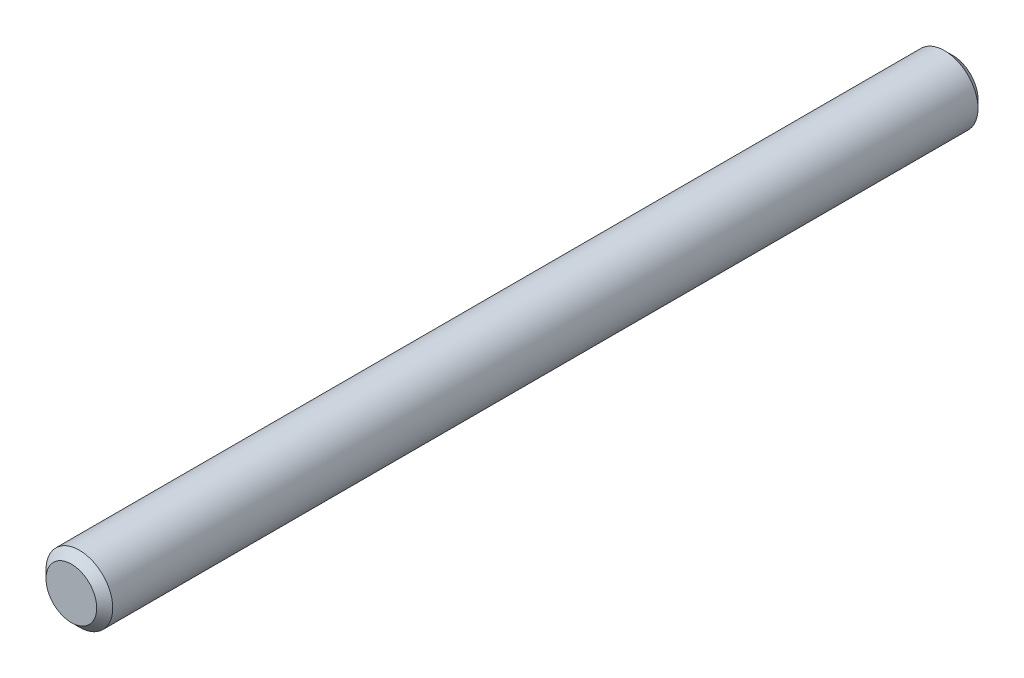
from build123d import *

# Parameters (mm, degrees)
SKETCH1_R           = 12.5
BOSS_EXTRUDE1_DEPTH = 165
CHAMFER1_SIZE       = 3


with BuildPart() as part:
    # Sketch1 → Boss-Extrude1 (new body, symmetric)
    with BuildSketch(Plane.XY):
        Circle(SKETCH1_R)
    extrude(amount=BOSS_EXTRUDE1_DEPTH, both=True)

    # Chamfer1
    chamfer1_edges = [part.edges().sort_by_distance(p)[0] for p in [
        (-12.5, 0, -165),
        (-12.5, 0, 165),
    ]]
    chamfer(chamfer1_edges, length=CHAMFER1_SIZE)


solid = part.part
